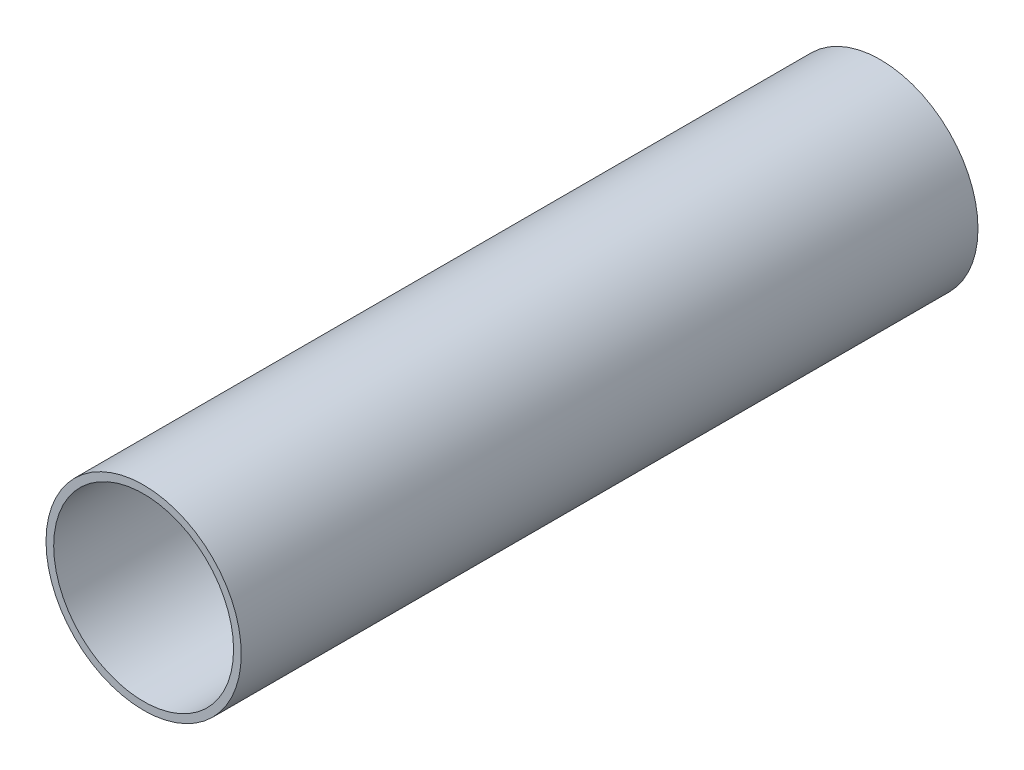
from build123d import *

# Parameters (mm, degrees)
SKETCH1_R           = 15.9
SKETCH1_R_2         = 14.65
BOSS_EXTRUDE1_DEPTH = 120


with BuildPart() as part:
    # Sketch1 → Boss-Extrude1 (new body)
    with BuildSketch(Plane.XY):
        Circle(SKETCH1_R)
        Circle(SKETCH1_R_2, mode=Mode.SUBTRACT)
    extrude(amount=-BOSS_EXTRUDE1_DEPTH)


solid = part.part
